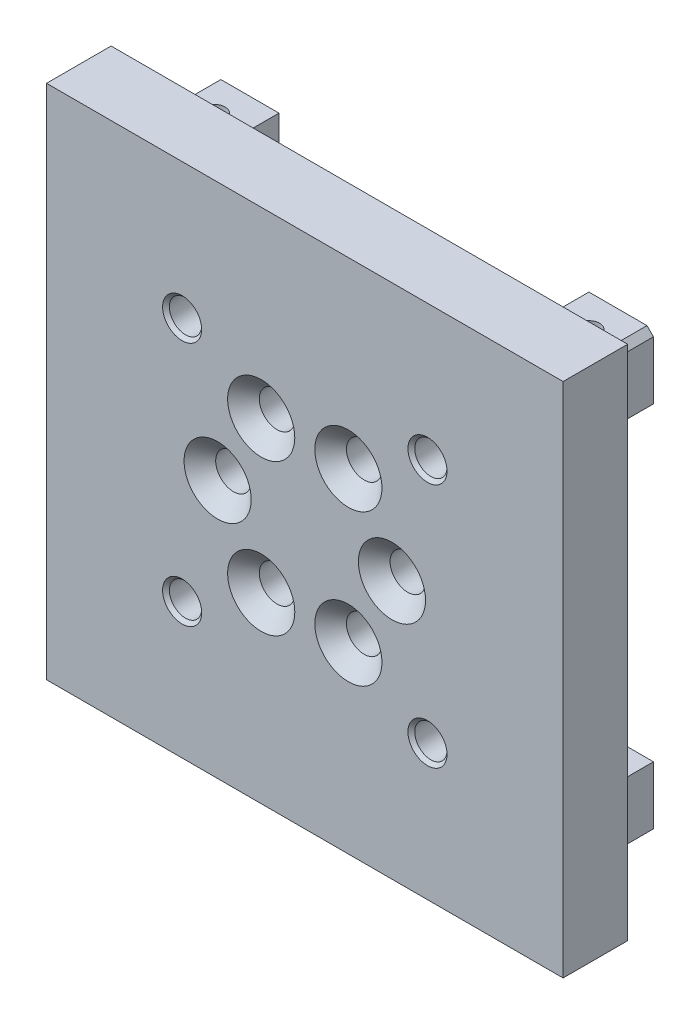
from build123d import *

# Parameters (mm, degrees)
SKETCH_1_W                   = 80
SKETCH_1_H                   = 80
EXTRUDE_1_DEPTH              = 10
SKETCH_11_W                  = 10
SKETCH_11_H                  = 10
EXTRUDE_3_DEPTH              = 10
HOLE_WIZARD_M4_2_D           = 3.3
HOLE_WIZARD_M4_2_DEPTH       = 68
HOLE_WIZARD_M5_1_D           = 5.5
HOLE_WIZARD_M5_1_DEPTH       = 10
HOLE_WIZARD_M5_1_CSINK_D     = 10.4
HOLE_WIZARD_M5_1_CSINK_ANGLE = 90
HOLE_WIZARD_M6_1_D           = 5
HOLE_WIZARD_M6_1_DEPTH       = 10
HOLE_WIZARD_M6_1_CSINK_D     = 6.05
HOLE_WIZARD_M6_1_CSINK_ANGLE = 90
MIRROR_2_COPY_1_SKETCH_W     = 10
MIRROR_2_COPY_1_SKETCH_H     = 10
MIRROR_2_COPY_1_DEPTH        = 10
MIRROR_2_COPY_2_D            = 3.3
MIRROR_2_COPY_2_DEPTH        = 68
CHAMFER_1_SIZE               = 1


with BuildPart() as part:
    # 스케치1 → 보스-돌출1 (new body)
    with BuildSketch(Plane.XY):
        Rectangle(SKETCH_1_W, SKETCH_1_H)
    extrude(amount=EXTRUDE_1_DEPTH)

    # 스케치11 → 보스-돌출3 (add)
    with BuildSketch(Plane(origin=(0, 0, 0), x_dir=(-1, 0, 0), z_dir=(0, 0, -1))):
        with Locations((29, 29)):
            Rectangle(SKETCH_11_W, SKETCH_11_H)
    extrude_3 = extrude(amount=EXTRUDE_3_DEPTH)

    # M4 나사 구멍2
    with Locations(Plane(origin=(0, 34, 0), x_dir=(1, 0, 0), z_dir=(0, 1, 0))):
        with Locations((-29, 5)):
            hole_wizard_m4_2 = Hole(HOLE_WIZARD_M4_2_D / 2, depth=HOLE_WIZARD_M4_2_DEPTH)

    # M5 접시 머리 나사용 카운터싱크1
    with Locations(Plane.XY.offset(10)):
        with Locations((-6.75, 11.691342951), (-13.5, 0), (-6.75, -11.691342951), (6.75, -11.691342951), (13.5, 0), (6.75, 11.691342951)):
            CounterSinkHole(HOLE_WIZARD_M5_1_D / 2, HOLE_WIZARD_M5_1_CSINK_D / 2, depth=HOLE_WIZARD_M5_1_DEPTH, counter_sink_angle=HOLE_WIZARD_M5_1_CSINK_ANGLE)

    # M6 나사 구멍1
    with Locations(Plane.XY.offset(10)):
        with Locations((-19, -19), (19, -19), (19, 19), (-19, 19)):
            CounterSinkHole(HOLE_WIZARD_M6_1_D / 2, HOLE_WIZARD_M6_1_CSINK_D / 2, depth=HOLE_WIZARD_M6_1_DEPTH, counter_sink_angle=HOLE_WIZARD_M6_1_CSINK_ANGLE)

    # 대칭 복사1: 보스-돌출3, M4 나사 구멍2 across plane
    add(extrude_3.mirror(Plane(origin=(0, 0, 0), x_dir=(0, 0, 1), z_dir=(1, 0, 0))))
    add(hole_wizard_m4_2.mirror(Plane(origin=(0, 0, 0), x_dir=(0, 0, 1), z_dir=(1, 0, 0))), mode=Mode.SUBTRACT)

    # 대칭 복사2: 보스-돌출3, M4 나사 구멍2 across plane
    add(extrude_3.mirror(Plane.ZX))
    add(hole_wizard_m4_2.mirror(Plane.ZX), mode=Mode.SUBTRACT)

    # 대칭 복사2 copy 1 sketch → 대칭 복사2 copy 1 (add)
    with BuildSketch(Plane(origin=(0, 0, 0), x_dir=(1, 0, 0), z_dir=(0, 0, -1))):
        with Locations((29, 29)):
            Rectangle(MIRROR_2_COPY_1_SKETCH_W, MIRROR_2_COPY_1_SKETCH_H)
    extrude(amount=MIRROR_2_COPY_1_DEPTH)

    # 대칭 복사2 copy 2
    with Locations(Plane(origin=(0, -34, 0), x_dir=(-1, 0, 0), z_dir=(0, -1, 0))):
        with Locations((-29, 5)):
            Hole(MIRROR_2_COPY_2_D / 2, depth=MIRROR_2_COPY_2_DEPTH)

    # 모따기1
    chamfer_1_edges = [part.edges().sort_by_distance(p)[0] for p in [
        (34, 34, -5),
        (34, -34, -5),
        (-34, -34, -5),
        (-34, 34, -5),
    ]]
    chamfer(chamfer_1_edges, length=CHAMFER_1_SIZE)


solid = part.part
